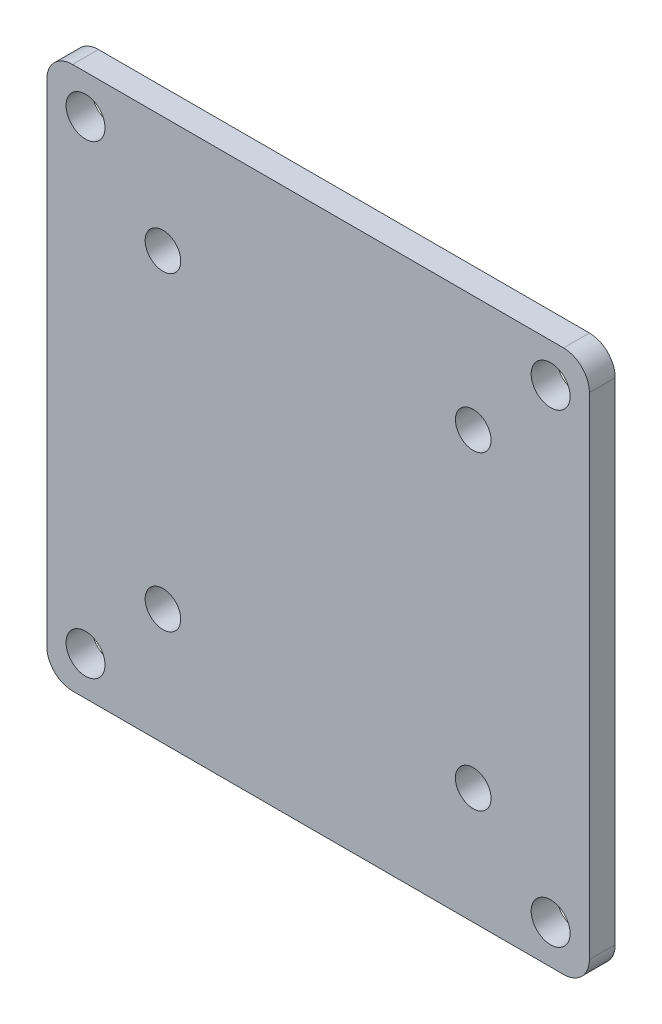
from build123d import *

# Parameters (mm, degrees)
SKETCH1_W           = 53.34
SKETCH1_H           = 53.34
SKETCH1_R           = 1.9145
SKETCH1_R_2         = 1.75
BOSS_EXTRUDE1_DEPTH = 2.54
FILLET1_R           = 2.54


with BuildPart() as part:
    # Sketch1 → Boss-Extrude1 (new body)
    with BuildSketch(Plane(origin=(0, 0, 0), x_dir=(0, 1, 0), z_dir=(0, 0, 1))):
        Rectangle(SKETCH1_W, SKETCH1_H)
        with Locations((-22.86, -22.86)):
            Circle(SKETCH1_R, mode=Mode.SUBTRACT)
        with Locations((22.86, -22.86)):
            Circle(SKETCH1_R, mode=Mode.SUBTRACT)
        with Locations((22.86, 22.86)):
            Circle(SKETCH1_R, mode=Mode.SUBTRACT)
        with Locations((-22.86, 22.86)):
            Circle(SKETCH1_R, mode=Mode.SUBTRACT)
        with Locations((-15.25, 15.25)):
            Circle(SKETCH1_R_2, mode=Mode.SUBTRACT)
        with Locations((15.25, 15.25)):
            Circle(SKETCH1_R_2, mode=Mode.SUBTRACT)
        with Locations((15.25, -15.25)):
            Circle(SKETCH1_R_2, mode=Mode.SUBTRACT)
        with Locations((-15.25, -15.25)):
            Circle(SKETCH1_R_2, mode=Mode.SUBTRACT)
    extrude(amount=BOSS_EXTRUDE1_DEPTH)

    # Fillet1
    fillet1_edges = [part.edges().sort_by_distance(p)[0] for p in [
        (-26.67, -26.67, 1.27),
        (-26.67, 26.67, 1.27),
        (26.67, 26.67, 1.27),
        (26.67, -26.67, 1.27),
    ]]
    fillet(fillet1_edges, radius=FILLET1_R)


solid = part.part
